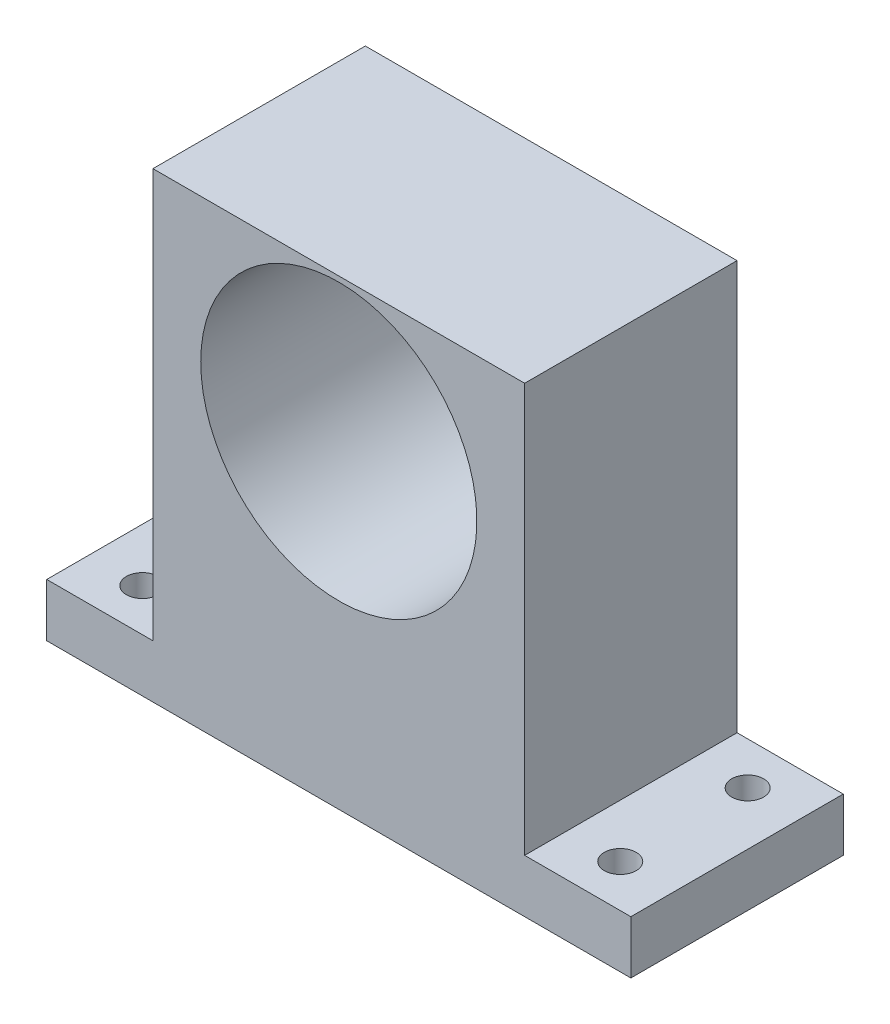
from build123d import *

# Parameters (mm, degrees)
SKETCH_1_W          = 35
SKETCH_1_H          = 43.5
EXTRUDE_1_DEPTH     = 20
SKETCH_2_W          = 20
SKETCH_2_H          = 5
EXTRUDE_2_DEPTH     = 10
SKETCH_3_W          = 20
SKETCH_3_H          = 5
EXTRUDE_3_DEPTH     = 10
SKETCH_4_R          = 1.5
CUT_EXTRUDE_2_DEPTH = 5
SKETCH_5_R          = 13
CUT_EXTRUDE_3_DEPTH = 20


with BuildPart() as part:
    # Эскиз1 → Бобышка-Вытянуть1 (new body)
    with BuildSketch(Plane.XY):
        Rectangle(SKETCH_1_W, SKETCH_1_H)
    extrude(amount=EXTRUDE_1_DEPTH)

    # Эскиз2 → Бобышка-Вытянуть2 (add)
    with BuildSketch(Plane(origin=(17.5, 0, 0), x_dir=(0, 0, -1), z_dir=(1, 0, 0))):
        with Locations((-10, -19.25)):
            Rectangle(SKETCH_2_W, SKETCH_2_H)
    extrude(amount=EXTRUDE_2_DEPTH)

    # Эскиз3 → Бобышка-Вытянуть3 (add)
    with BuildSketch(Plane.ZY.offset(17.5)):
        with Locations((10, -19.25)):
            Rectangle(SKETCH_3_W, SKETCH_3_H)
    extrude(amount=EXTRUDE_3_DEPTH)

    # Эскиз4 → Вырез-Вытянуть2 (cut)
    with BuildSketch(Plane(origin=(0, -16.75, 0), x_dir=(1, 0, 0), z_dir=(0, 1, 0))):
        with Locations((-22.5, -16)):
            Circle(SKETCH_4_R)
        with Locations((-22.5, -4)):
            Circle(SKETCH_4_R)
        with Locations((22.5, -16)):
            Circle(SKETCH_4_R)
        with Locations((22.5, -4)):
            Circle(SKETCH_4_R)
    extrude(amount=-CUT_EXTRUDE_2_DEPTH, mode=Mode.SUBTRACT)

    # Эскиз5 → Вырез-Вытянуть3 (cut)
    with BuildSketch(Plane(origin=(0, 0, 0), x_dir=(-1, 0, 0), z_dir=(0, 0, -1))):
        with Locations((0, 8.25)):
            Circle(SKETCH_5_R)
    extrude(amount=-CUT_EXTRUDE_3_DEPTH, mode=Mode.SUBTRACT)


solid = part.part
